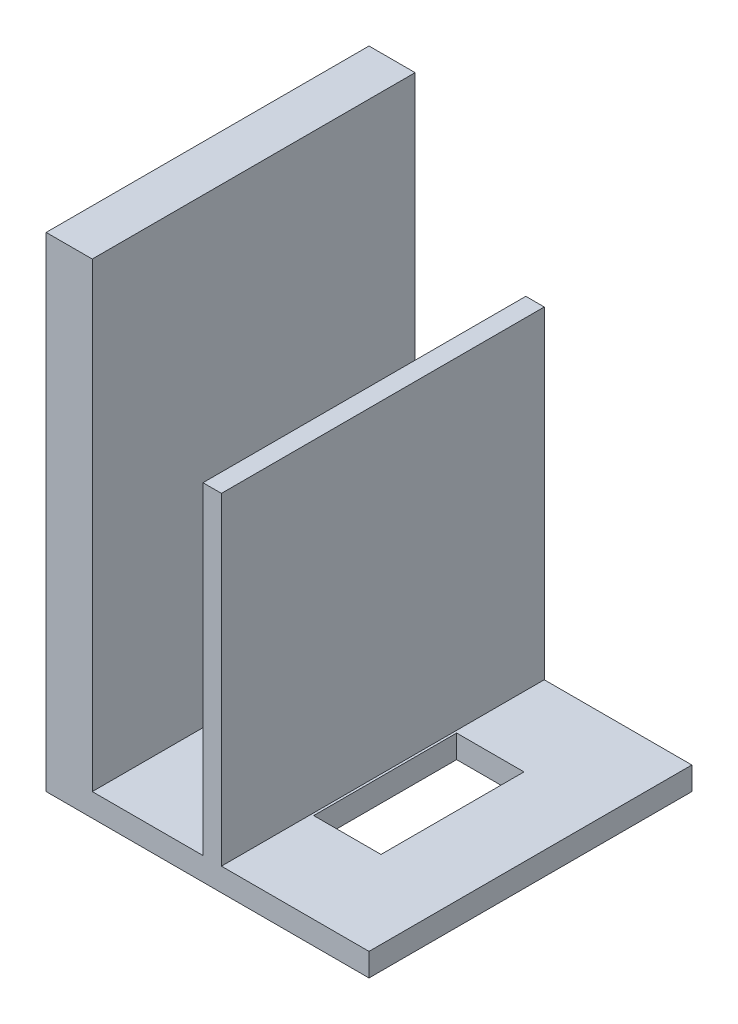
from build123d import *

# Parameters (mm, degrees)
SKETCH1_W           = 35
SKETCH1_H           = 35
BOSS_EXTRUDE1_DEPTH = 2.5
SKETCH2_W           = 5
SKETCH2_H           = 35
BOSS_EXTRUDE2_DEPTH = 50
SKETCH5_W           = 17
SKETCH5_H           = 35
CUT_EXTRUDE2_DEPTH  = 4
SKETCH6_R           = 5
CUT_EXTRUDE3_DEPTH  = 10
SKETCH7_W           = 2
SKETCH7_H           = 35
BOSS_EXTRUDE3_DEPTH = 35
SKETCH8_W           = 7.3
SKETCH8_H           = 15.5
CUT_EXTRUDE4_DEPTH  = 3.5


with BuildPart() as part:
    # Sketch1 → Boss-Extrude1 (new body)
    with BuildSketch(Plane(origin=(0, 0, 0), x_dir=(1, 0, 0), z_dir=(0, 1, 0))):
        with Locations((17.5, 17.5)):
            Rectangle(SKETCH1_W, SKETCH1_H)
    extrude(amount=BOSS_EXTRUDE1_DEPTH)

    # Sketch2 → Boss-Extrude2 (add)
    with BuildSketch(Plane(origin=(0, 2.5, 0), x_dir=(1, 0, 0), z_dir=(0, 1, 0))):
        with Locations((2.5, 17.5)):
            Rectangle(SKETCH2_W, SKETCH2_H)
    extrude(amount=BOSS_EXTRUDE2_DEPTH)

    # Sketch5 → Cut-Extrude2 (cut)
    with BuildSketch(Plane.ZY):
        with Locations((-17.553851225, 30)):
            Rectangle(SKETCH5_W, SKETCH5_H)
    extrude(amount=-CUT_EXTRUDE2_DEPTH, mode=Mode.SUBTRACT)

    # Sketch6 → Cut-Extrude3 (cut)
    with BuildSketch(Plane(origin=(0, 2.5, 0), x_dir=(1, 0, 0), z_dir=(0, 1, 0))):
        with Locations((10.75, 17.5)):
            Circle(SKETCH6_R)
    extrude(amount=-CUT_EXTRUDE3_DEPTH, mode=Mode.SUBTRACT)

    # Sketch7 → Boss-Extrude3 (add)
    with BuildSketch(Plane(origin=(0, 2.5, 0), x_dir=(1, 0, 0), z_dir=(0, 1, 0))):
        with Locations((18, 17.5)):
            Rectangle(SKETCH7_W, SKETCH7_H)
    extrude(amount=BOSS_EXTRUDE3_DEPTH)

    # Sketch8 → Cut-Extrude4 (cut, through all)
    with BuildSketch(Plane(origin=(0, 2.5, 0), x_dir=(1, 0, 0), z_dir=(0, 1, 0))):
        with Locations((22.9, 17.5)):
            Rectangle(SKETCH8_W, SKETCH8_H)
    extrude(amount=-CUT_EXTRUDE4_DEPTH, mode=Mode.SUBTRACT)


solid = part.part
